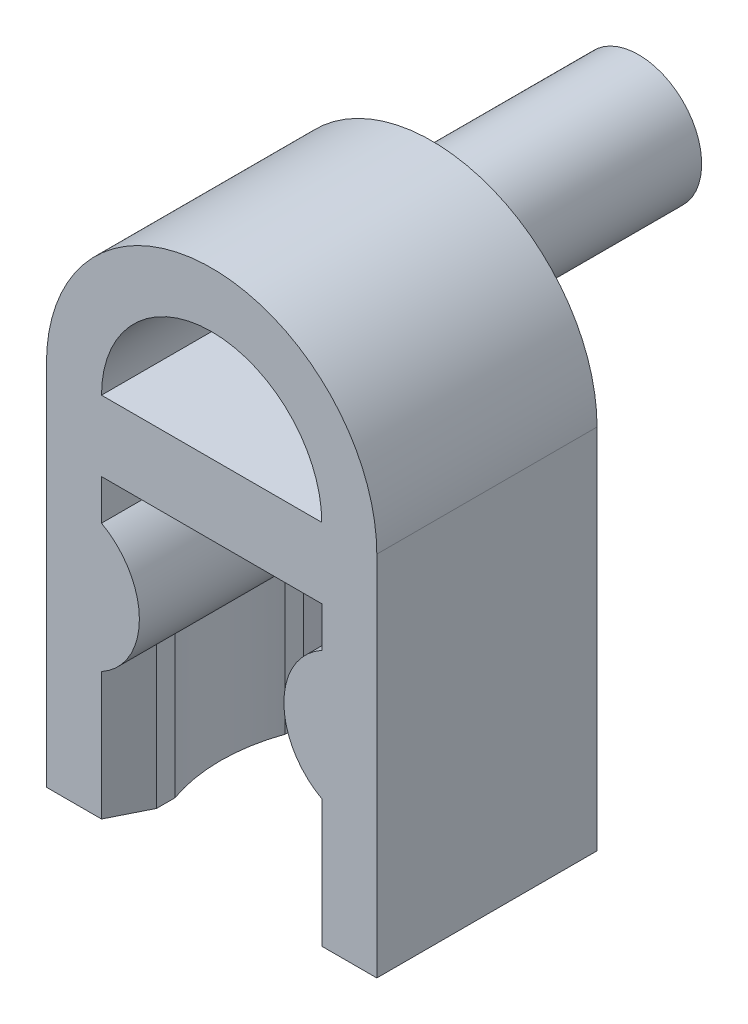
from build123d import *

# Parameters (mm, degrees)
EXTRUDE_1_DEPTH     = 6
CUT_EXTRUDE_1_DEPTH = 4
SKETCH_3_R          = 1.72
EXTRUDE_2_DEPTH     = 5.63
EXTRUDE_5_REACH     = 16.5


with BuildPart() as part:
    # 草图1 → 凸台-拉伸1 (new body)
    with BuildSketch(Plane.XY):
        with BuildLine():
            Line((4.5, 0), (4.5, -10))
            Line((4.5, -10), (3, -10))
            Line((3, -10), (3, -6.52))
            ThreePointArc((3, -6.52), (1.968245837, -4.77), (3, -3.02))
            Line((3, -3.02), (3, -1.92))
            Line((3, -1.92), (-3, -1.92))
            Line((-3, -1.92), (-3, -3.02))
            ThreePointArc((-3, -3.02), (-1.968245837, -4.77), (-3, -6.52))
            Line((-3, -6.52), (-3, -10))
            Line((-3, -10), (-4.5, -10))
            Line((-4.5, -10), (-4.5, 0))
            ThreePointArc((-4.5, 0), (0, 4.5), (4.5, 0))
        make_face()
    extrude(amount=EXTRUDE_1_DEPTH)

    # 草图2 → 切除-拉伸1 (cut)
    with BuildSketch(Plane.XY.offset(6)):
        with BuildLine():
            Line((3, 0), (-3, 0))
            ThreePointArc((-3, 0), (0, 3), (3, 0))
        make_face()
    extrude(amount=-CUT_EXTRUDE_1_DEPTH, mode=Mode.SUBTRACT)

    # 草图3 → 凸台-拉伸2 (add)
    with BuildSketch(Plane(origin=(0, 0, 0), x_dir=(-1, 0, 0), z_dir=(0, 0, -1))):
        with Locations((0, 2)):
            Circle(SKETCH_3_R)
    extrude(amount=EXTRUDE_2_DEPTH)

    # 草图4 → 凸台-拉伸5 (add, up to next)
    with BuildSketch(Plane.XZ.offset(10), mode=Mode.PRIVATE) as extrude_5_sk1:
        with BuildLine():
            Line((-3, 0), (-3, 6))
            Line((-3, 6), (-2.5, 5))
            Line((-2.5, 5), (-2.5, 4.5))
            ThreePointArc((-2.5, 4.5), (-2.757359313, 3), (-2.5, 1.5))
            Line((-2.5, 1.5), (-2.5, 1))
            Line((-2.5, 1), (-3, 0))
        make_face()
    extrude_5_tool1 = extrude(extrude_5_sk1.sketch, amount=-EXTRUDE_5_REACH, mode=Mode.PRIVATE) - part.part
    add(extrude_5_tool1.solids().sort_by_distance((-2.809362, -10, 3))[0])
    # 草图4 → 凸台-拉伸5 (add, up to next)
    with BuildSketch(Plane.XZ.offset(10), mode=Mode.PRIVATE) as extrude_5_sk2:
        with BuildLine():
            Line((2.5, 5), (2.5, 4.5))
            ThreePointArc((2.5, 4.5), (2.757359313, 3), (2.5, 1.5))
            Line((2.5, 1.5), (2.5, 1))
            Line((2.5, 1), (3, 0))
            Line((3, 0), (3, 6))
            Line((3, 6), (2.5, 5))
        make_face()
    extrude_5_tool2 = extrude(extrude_5_sk2.sketch, amount=-EXTRUDE_5_REACH, mode=Mode.PRIVATE) - part.part
    add(extrude_5_tool2.solids().sort_by_distance((2.809362, -10, 3))[0])


solid = part.part
